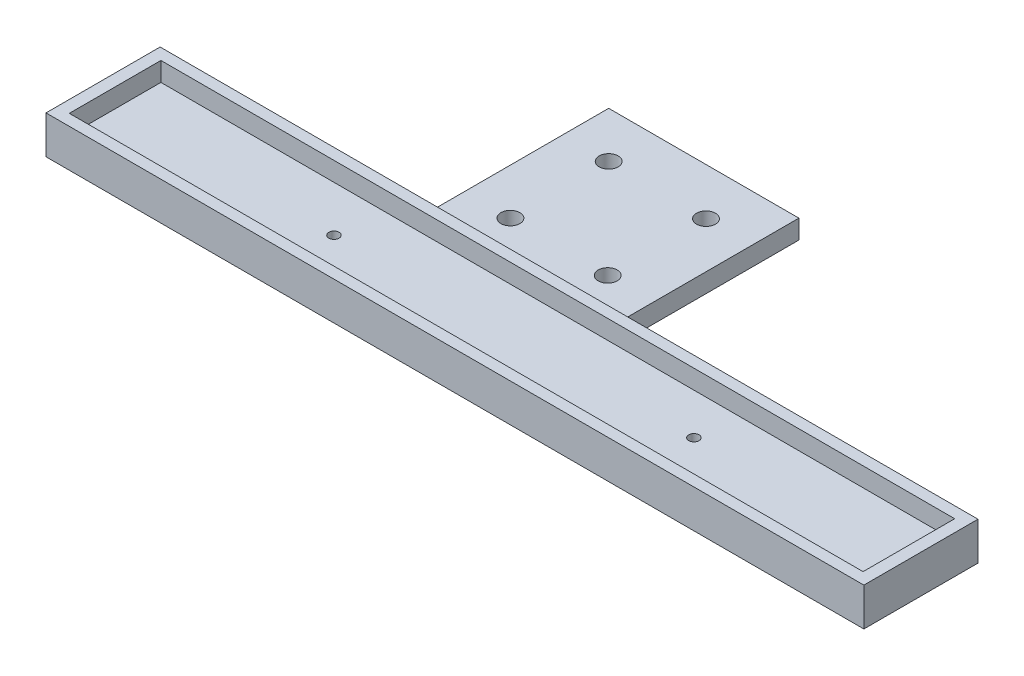
from build123d import *

# Parameters (mm, degrees)
SKETCH1_W           = 129
SKETCH1_H           = 18
SKETCH1_W_2         = 125.2
SKETCH1_H_2         = 14.45
BOSS_EXTRUDE1_DEPTH = 3
SKETCH2_W           = 129
SKETCH2_H           = 18
BOSS_EXTRUDE2_DEPTH = 3
SKETCH4_R           = 0.81
CUT_EXTRUDE1_DEPTH  = 4
SKETCH5_W           = 30
SKETCH5_H           = 30
SKETCH5_R           = 1.5
BOSS_EXTRUDE4_DEPTH = 3


with BuildPart() as part:
    # Sketch1 → Boss-Extrude1 (new body)
    with BuildSketch(Plane(origin=(0, 0, 0), x_dir=(1, 0, 0), z_dir=(0, 1, 0))):
        Rectangle(SKETCH1_W, SKETCH1_H)
        Rectangle(SKETCH1_W_2, SKETCH1_H_2, mode=Mode.SUBTRACT)
    extrude(amount=BOSS_EXTRUDE1_DEPTH)

    # Sketch2 → Boss-Extrude2 (add)
    with BuildSketch(Plane.XZ):
        Rectangle(SKETCH2_W, SKETCH2_H)
    extrude(amount=BOSS_EXTRUDE2_DEPTH)

    # Sketch4 → Cut-Extrude1 (cut, through all)
    with BuildSketch(Plane(origin=(0, 0, 0), x_dir=(1, 0, 0), z_dir=(0, 1, 0))):
        with Locations((27.97, 0.725)):
            Circle(SKETCH4_R)
        with Locations((-28.08, 0)):
            Circle(SKETCH4_R)
    extrude(amount=-CUT_EXTRUDE1_DEPTH, mode=Mode.SUBTRACT)

    # Sketch5 → Boss-Extrude4 (add)
    with BuildSketch(Plane.XZ.offset(3)):
        with Locations((-8.75, -24)):
            Rectangle(SKETCH5_W, SKETCH5_H)
        with Locations((-1, -16.092702878)):
            Circle(SKETCH5_R, mode=Mode.SUBTRACT)
        with Locations((-1.000798162, -31.592702857)):
            Circle(SKETCH5_R, mode=Mode.SUBTRACT)
        with Locations((-16.5, -31.75)):
            Circle(SKETCH5_R, mode=Mode.SUBTRACT)
        with Locations((-16.499201838, -16.250000021)):
            Circle(SKETCH5_R, mode=Mode.SUBTRACT)
    extrude(amount=-BOSS_EXTRUDE4_DEPTH)


solid = part.part
